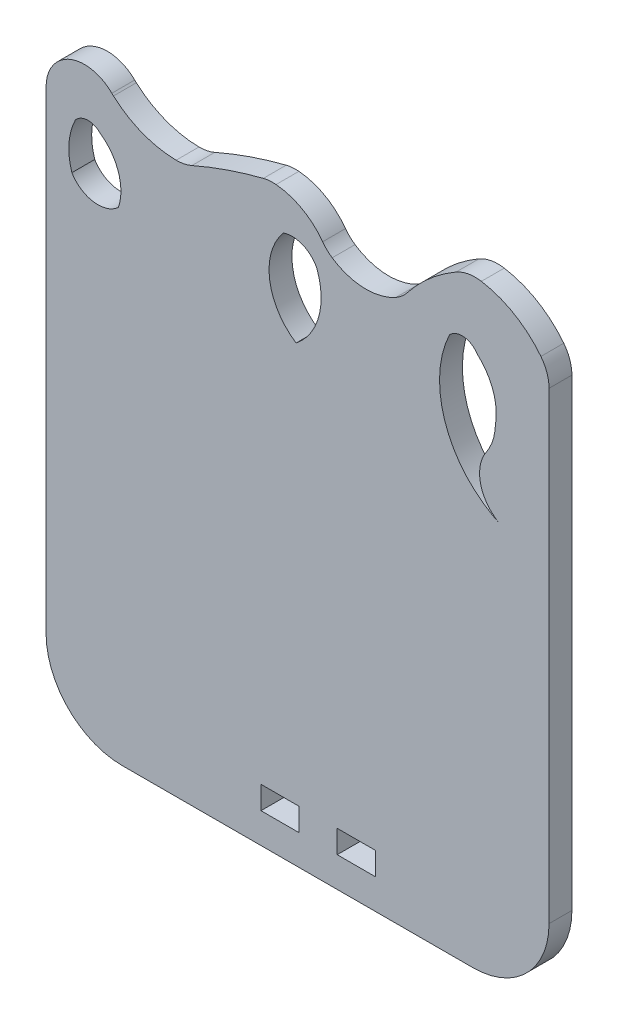
from build123d import *

# Parameters (mm, degrees)
MODEL_W                 = 5
MODEL_H                 = 3
SALIENTE_EXTRUIR1_DEPTH = 3


with BuildPart() as part:
    # Model → Saliente-Extruir1 (new body)
    with BuildSketch(Plane.XY):
        with BuildLine():
            Line((20.008207432, -12.939384908), (66.010263245, -12.893602043))
            ThreePointArc((66.010263245, -12.893602043), (73.073704766, -9.960505296), (75.998467898, -2.893608999))
            Line((75.998467898, -2.893608999), (75.998467898, 57.945785177))
            ThreePointArc((75.998467898, 57.945785177), (75.723996205, 59.579609591), (74.930715011, 61.034058584))
            ThreePointArc((74.930715011, 61.034058584), (71.458592106, 64.079128283), (67.120056098, 65.661908193))
            ThreePointArc((67.120056098, 65.661908193), (65.407202512, 65.649235175), (63.799137493, 65.059188646))
            ThreePointArc((63.799137493, 65.059188646), (60.321181429, 62.581168885), (57.375331255, 59.489449773))
            ThreePointArc((57.375331255, 59.489449773), (56.705233076, 58.78878229), (55.912510286, 58.230609316))
            ThreePointArc((55.912510286, 58.230609316), (51.681435493, 57.197439234), (47.539355907, 58.543771667))
            ThreePointArc((47.539355907, 58.543771667), (46.862531917, 59.089051576), (46.290360926, 59.743300191))
            ThreePointArc((46.290360926, 59.743300191), (43.606330835, 62.127791891), (40.177093566, 63.190877002))
            ThreePointArc((40.177093566, 63.190877002), (39.335519322, 63.193801481), (38.505375583, 63.055536752))
            ThreePointArc((38.505375583, 63.055536752), (33.752250549, 61.633947137), (29.132691698, 59.824861555))
            ThreePointArc((29.132691698, 59.824861555), (28.121419114, 59.502877339), (27.064969356, 59.401585766))
            ThreePointArc((27.064969356, 59.401585766), (22.663084015, 60.24830335), (18.838325452, 62.585983217))
            ThreePointArc((18.838325452, 62.585983217), (18.72958465, 62.685805621), (18.623837896, 62.788794446))
            ThreePointArc((18.623837896, 62.788794446), (13.136237234, 63.897475715), (9.998466828, 59.260954168))
            Line((9.998466828, 59.260954168), (9.998466828, 49.801714137))
            Line((9.998466828, 49.801714137), (9.998466828, 5.563187374))
            Line((9.998466828, 5.563187374), (9.998466828, -2.939389652))
            ThreePointArc((9.998466828, -2.939389652), (12.930843678, -10.013900449), (20.008207432, -12.939384908))
        make_face()
        with Locations((40.698466828, -7.45894512)):
            Rectangle(MODEL_W, MODEL_H, mode=Mode.SUBTRACT)
        with Locations((50.698466828, -7.45894512)):
            Rectangle(MODEL_W, MODEL_H, mode=Mode.SUBTRACT)
        with BuildLine():
            ThreePointArc((13.38150499, 51.138785491), (16.223261536, 49.248187955), (19.489283729, 50.239670854))
            ThreePointArc((19.489283729, 50.239670854), (19.489133726, 54.270134742), (17.070975396, 57.494595853))
            ThreePointArc((17.070975396, 57.494595853), (15.431399569, 58.144215006), (13.846564285, 57.370580041))
            ThreePointArc((13.846564285, 57.370580041), (13.001415993, 54.300400575), (13.38150499, 51.138785491))
        make_face(mode=Mode.SUBTRACT)
        with BuildLine():
            ThreePointArc((42.8061835, 46.49607523), (45.78666607, 50.989901686), (45.513041105, 56.375334067))
            ThreePointArc((45.513041105, 56.375334067), (43.667852236, 58.087404125), (41.152011526, 58.167724535))
            ThreePointArc((41.152011526, 58.167724535), (39.330773735, 51.956564499), (42.8061835, 46.49607523))
        make_face(mode=Mode.SUBTRACT)
        with BuildLine():
            ThreePointArc((67.753301624, 46.561168422), (67.083996664, 42.334160171), (69.92982942, 39.137786632))
            ThreePointArc((69.92982942, 39.137786632), (62.518296186, 46.833384565), (62.941159785, 57.509256371))
            ThreePointArc((62.941159785, 57.509256371), (64.848153818, 58.200191525), (66.567104331, 57.123517589))
            ThreePointArc((66.567104331, 57.123517589), (68.661600931, 54.003474992), (68.958684777, 50.257367279))
            ThreePointArc((68.958684777, 50.257367279), (68.620238398, 48.323093723), (67.753301624, 46.561168422))
        make_face(mode=Mode.SUBTRACT)
    extrude(amount=SALIENTE_EXTRUIR1_DEPTH)


solid = part.part
